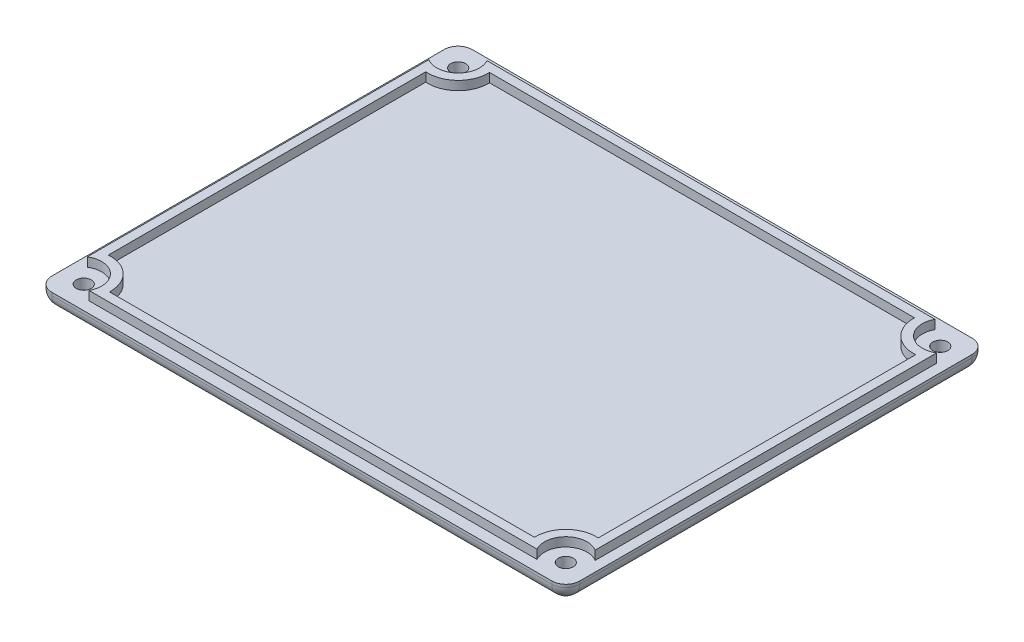
from build123d import *

# Parameters (mm, degrees)
SKETCH1_W                                       = 119.634
SKETCH1_H                                       = 95.25
BOSS_EXTRUDE1_DEPTH                             = 3.81
FILLET1_R                                       = 3.175
BOSS_EXTRUDE2_DEPTH                             = 2.032
CSK_FOR_M3_FLAT_HEAD_MACHINE_SCREW1_D           = 3.4
CSK_FOR_M3_FLAT_HEAD_MACHINE_SCREW1_DEPTH       = 25.4
CSK_FOR_M3_FLAT_HEAD_MACHINE_SCREW1_CSINK_D     = 6.3
CSK_FOR_M3_FLAT_HEAD_MACHINE_SCREW1_CSINK_ANGLE = 90
CSK_FOR_M3_FLAT_HEAD_MACHINE_SCREW1_TIP         = 1.021463052


with BuildPart() as part:
    # Sketch1 → Boss-Extrude1 (new body)
    with BuildSketch(Plane(origin=(0, 0, 0), x_dir=(1, 0, 0), z_dir=(0, 1, 0))):
        with Locations((59.817, 47.625)):
            Rectangle(SKETCH1_W, SKETCH1_H)
    extrude(amount=BOSS_EXTRUDE1_DEPTH)

    # Fillet1
    fillet1_edges = [part.edges().sort_by_distance(p)[0] for p in [
        (59.817, 0, -95.25),
        (119.634, 0, -47.625),
        (59.817, 0, 0),
        (0, 0, -47.625),
        (0, 1.905, -95.25),
        (119.634, 1.905, -95.25),
        (119.634, 1.905, 0),
        (0, 1.905, 0),
    ]]
    fillet(fillet1_edges, radius=FILLET1_R)

    # Sketch2 → Boss-Extrude2 (add)
    with BuildSketch(Plane(origin=(0, 3.81, 0), x_dir=(1, 0, 0), z_dir=(0, 1, 0))):
        with BuildLine():
            Line((9.076232935, 92.71), (110.557767065, 92.71))
            ThreePointArc((110.557767065, 92.71), (111.500790054, 86.90936796), (117.348, 86.320504417))
            Line((117.348, 86.320504417), (117.348, 8.929495583))
            ThreePointArc((117.348, 8.929495583), (111.500790054, 8.34063204), (110.557767065, 2.54))
            Line((110.557767065, 2.54), (9.076232935, 2.54))
            ThreePointArc((9.076232935, 2.54), (8.133209946, 8.34063204), (2.286, 8.929495583))
            Line((2.286, 8.929495583), (2.286, 86.320504417))
            ThreePointArc((2.286, 86.320504417), (8.133209946, 86.90936796), (9.076232935, 92.71))
        make_face()
        with BuildLine():
            Line((11.679294682, 90.678), (107.954705318, 90.678))
            ThreePointArc((107.954705318, 90.678), (110.049437362, 85.485554332), (115.316, 83.584840695))
            Line((115.316, 83.584840695), (115.316, 11.665159305))
            ThreePointArc((115.316, 11.665159305), (110.049437362, 9.764445668), (107.954705318, 4.572))
            Line((107.954705318, 4.572), (11.679294682, 4.572))
            ThreePointArc((11.679294682, 4.572), (9.584562638, 9.764445668), (4.318, 11.665159305))
            Line((4.318, 11.665159305), (4.318, 83.584840695))
            ThreePointArc((4.318, 83.584840695), (9.584562638, 85.485554332), (11.679294682, 90.678))
        make_face(mode=Mode.SUBTRACT)
    extrude(amount=BOSS_EXTRUDE2_DEPTH)

    # CSK for M3 Flat Head Machine Screw1
    with Locations(Plane(origin=(0, 0, 0), x_dir=(-1, 0, 0), z_dir=(0, -1, 0))):
        with Locations((-114.427, 5.207), (-5.207, 5.207), (-5.207, 90.043), (-114.427, 90.043)):
            CounterSinkHole(CSK_FOR_M3_FLAT_HEAD_MACHINE_SCREW1_D / 2, CSK_FOR_M3_FLAT_HEAD_MACHINE_SCREW1_CSINK_D / 2, depth=CSK_FOR_M3_FLAT_HEAD_MACHINE_SCREW1_DEPTH, counter_sink_angle=CSK_FOR_M3_FLAT_HEAD_MACHINE_SCREW1_CSINK_ANGLE)
            with Locations((0, 0, -(CSK_FOR_M3_FLAT_HEAD_MACHINE_SCREW1_DEPTH + CSK_FOR_M3_FLAT_HEAD_MACHINE_SCREW1_TIP / 2))):  # 118° drill point
                Cone(0, CSK_FOR_M3_FLAT_HEAD_MACHINE_SCREW1_D / 2, CSK_FOR_M3_FLAT_HEAD_MACHINE_SCREW1_TIP, mode=Mode.SUBTRACT)


solid = part.part
